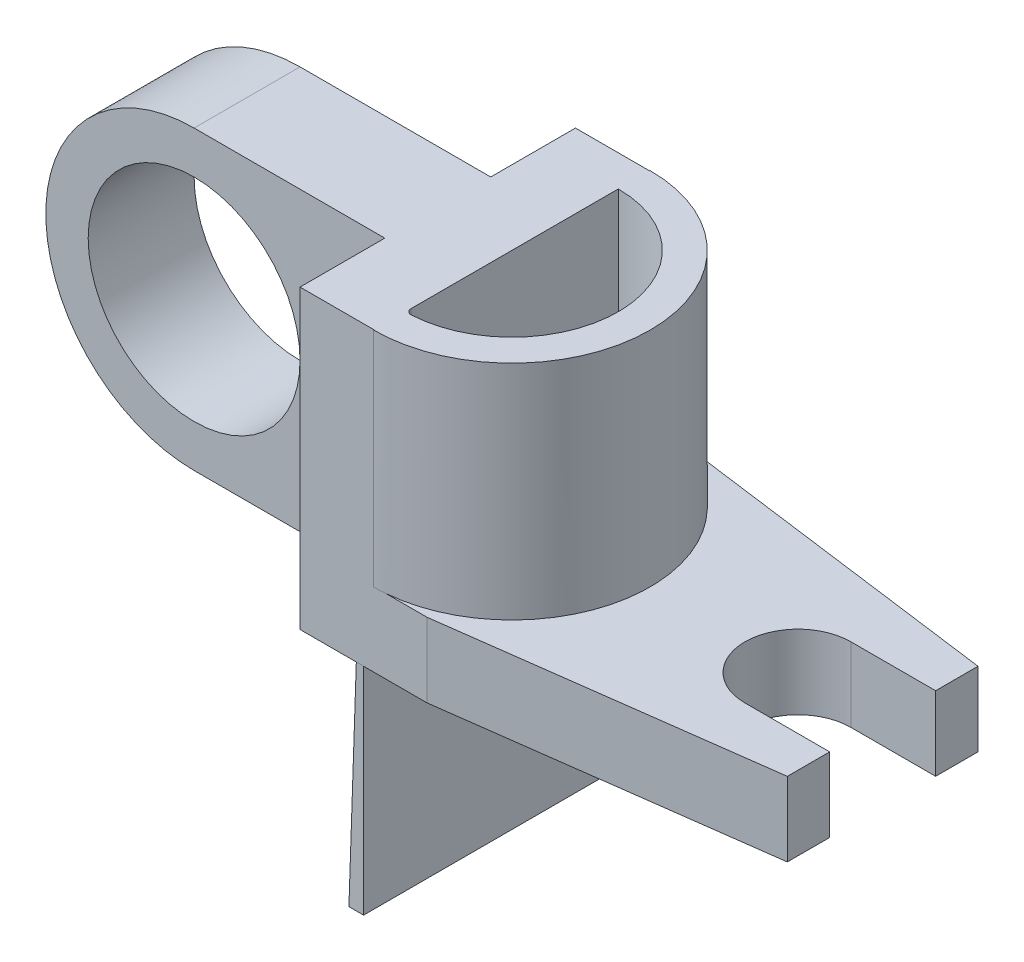
from build123d import *

# Parameters (mm, degrees)
SZKIC1_R                              = 10
DODANIE_WYCI_GNI_CIE1_DEPTH           = 10
DODANIE_WYCI_GNI_CIE2_DEPTH           = 7
SZKIC3_W                              = 26
SZKIC3_H                              = 7
DODANIE_WYCI_GNI_CIE3_DEPTH           = 5
DODANIE_WYCI_GNI_CIE4_DEPTH           = 7
DODANIE_WYCI_GNI_CIE5_DEPTH           = 21
ZAOKR_GLENIE2_R                       = 0.5
SZKIC8_W                              = 0.687995553
SZKIC8_H                              = 26
DODANIE_WYCI_GNI_CIE6_DEPTH           = 20
DODANIE_WYCI_GNI_CIE6_TAPER           = -1
DODANIE_WYCI_GNI_CIE6_OTHER_WAY_DEPTH = 10


with BuildPart() as part:
    # Szkic1 → Dodanie-wyciągnięcie1 (new body)
    with BuildSketch(Plane.XY):
        with BuildLine():
            Line((-10.593939394, 20.448484848), (-10.593939394, -7.551515152))
            Line((-10.593939394, -7.551515152), (-28.593939394, -7.551515152))
            ThreePointArc((-28.593939394, -7.551515152), (-42.593939394, 6.448484848), (-28.593939394, 20.448484848))
            Line((-28.593939394, 20.448484848), (-10.593939394, 20.448484848))
        make_face()
        with Locations((-28.593939394, 6.448484848)):
            Circle(SZKIC1_R, mode=Mode.SUBTRACT)
    extrude(amount=DODANIE_WYCI_GNI_CIE1_DEPTH)

    # Szkic2 → Dodanie-wyciągnięcie2 (add)
    with BuildSketch(Plane(origin=(-10.593939394, 0, 0), x_dir=(0, 0, -1), z_dir=(1, 0, 0))):
        Polygon((-10, 20.448484848), (-18, 20.448484848), (-18, -7.551515152), (-10, -7.551515152), (0, -7.551515152), (8, -7.551515152), (8, 20.448484848), (0, 20.448484848), align=None)
    extrude(amount=DODANIE_WYCI_GNI_CIE2_DEPTH)

    # Szkic3 → Dodanie-wyciągnięcie3 (add)
    with BuildSketch(Plane(origin=(-3.593939394, 0, 0), x_dir=(0, 0, -1), z_dir=(1, 0, 0))):
        with Locations((-5, -4.051515152)):
            Rectangle(SZKIC3_W, SZKIC3_H)
    extrude(amount=DODANIE_WYCI_GNI_CIE3_DEPTH)

    # Szkic4 → Dodanie-wyciągnięcie4 (add)
    with BuildSketch(Plane(origin=(0, -0.551515152, 0), x_dir=(1, 0, 0), z_dir=(0, 1, 0))):
        with BuildLine():
            Line((1.406060606, -18), (1.406060606, 8))
            Line((1.406060606, 8), (31.406060606, 4))
            Line((31.406060606, 4), (31.406060606, 0))
            Line((31.406060606, 0), (23.406060606, 0))
            ThreePointArc((23.406060606, 0), (18.406060606, -5), (23.406060606, -10))
            Line((23.406060606, -10), (31.406060606, -10))
            Line((31.406060606, -10), (31.406060606, -14))
            Line((31.406060606, -14), (1.406060606, -18))
        make_face()
    extrude(amount=-DODANIE_WYCI_GNI_CIE4_DEPTH)

    # Szkic5 → Dodanie-wyciągnięcie5 (add)
    with BuildSketch(Plane(origin=(0, -0.551515152, 0), x_dir=(1, 0, 0), z_dir=(0, 1, 0))):
        with BuildLine():
            Line((-3.593939394, 8.043944751), (-3.593939394, 5.043944751))
            ThreePointArc((-3.593939394, 5.043944751), (6.450005357, -5), (-3.593939394, -15.043944751))
            Line((-3.593939394, -15.043944751), (-3.593939394, -18.043944751))
            ThreePointArc((-3.593939394, -18.043944751), (9.450005357, -5), (-3.593939394, 8.043944751))
        make_face()
    extrude(amount=DODANIE_WYCI_GNI_CIE5_DEPTH)

    # Zaokrąglenie2
    zaokr_glenie2_edges = [part.edges().sort_by_distance(p)[0] for p in [
        (-3.593939394, 9.948484848, 15.043944751),
    ]]
    fillet(zaokr_glenie2_edges, radius=ZAOKR_GLENIE2_R)

    # Szkic8 → Dodanie-wyciągnięcie6 (add)
    with BuildSketch(Plane.XZ.offset(7.551515152)):
        with Locations((-4.937937171, 5)):
            Rectangle(SZKIC8_W, SZKIC8_H)
    extrude(amount=DODANIE_WYCI_GNI_CIE6_DEPTH, taper=DODANIE_WYCI_GNI_CIE6_TAPER)

    # Szkic8 → Dodanie-wyciągnięcie6 other way (add)
    with BuildSketch(Plane.XZ.offset(7.551515152)):
        with Locations((-4.937937171, 5)):
            Rectangle(SZKIC8_W, SZKIC8_H)
    extrude(amount=-DODANIE_WYCI_GNI_CIE6_OTHER_WAY_DEPTH)


solid = part.part
